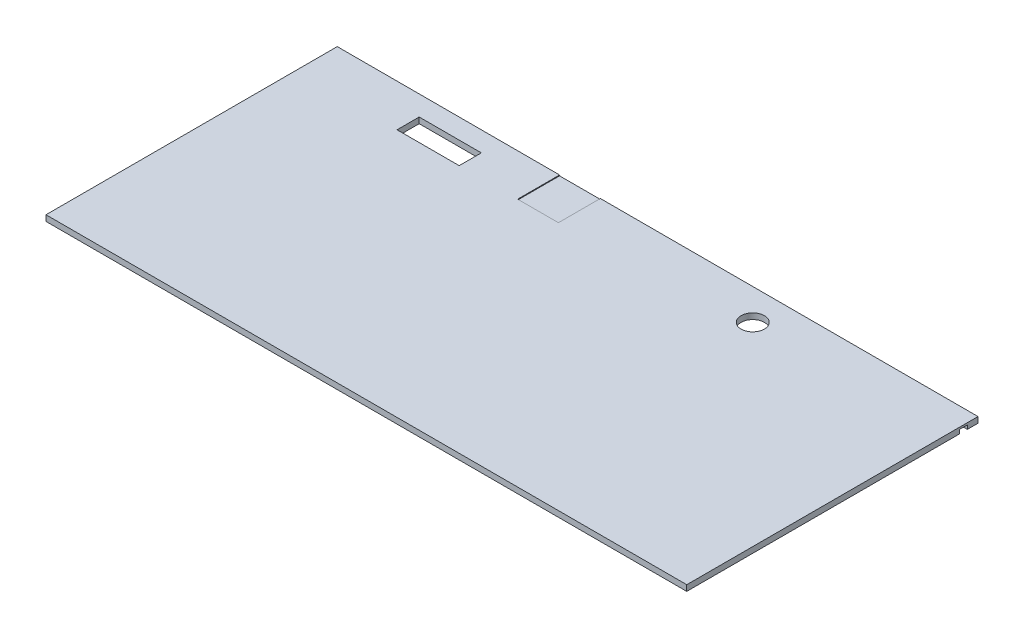
from build123d import *

# Parameters (mm, degrees)
SKETCH1_W           = 160
SKETCH1_H           = 57
SKETCH1_R           = 30
SKETCH1_W_2         = 105
SKETCH1_H_2         = 108
BOSS_EXTRUDE1_DEPTH = 15
CUT_EXTRUDE1_START  = -572.5
SKETCH2_W           = 20
SKETCH2_H           = 10
CUT_EXTRUDE1_DEPTH  = 497.5
CUT_EXTRUDE2_START  = -677.5
SKETCH2_3_W         = 20
SKETCH2_3_H         = 10
CUT_EXTRUDE2_DEPTH  = 973.5
CUT_EXTRUDE3_START  = 13
SKETCH1_3_W         = 105
SKETCH1_3_H         = 108
CUT_EXTRUDE3_DEPTH  = 3
CUT_EXTRUDE4_START  = -572.5
SKETCH2_4_W         = 20
SKETCH2_4_H         = 10
CUT_EXTRUDE4_DEPTH  = 497.5
CUT_EXTRUDE5_START  = -1250
SKETCH2_5_W         = 20
SKETCH2_5_H         = 10
CUT_EXTRUDE5_DEPTH  = 572.5
SKETCH4_W           = 20
SKETCH4_H           = 20
CUT_EXTRUDE6_DEPTH  = 5
SKETCH3_W           = 20
SKETCH3_H           = 600
CUT_EXTRUDE7_DEPTH  = 10


with BuildPart() as part:
    # Sketch1 → Boss-Extrude1 (new body)
    with BuildSketch(Plane(origin=(0, 0, 0), x_dir=(1, 0, 0), z_dir=(0, 1, 0))):
        Polygon((-825, 375), (-825, -375), (825, -375), (825, 375), (-147.5, 375), (-147.5, 267), (-252.5, 267), (-252.5, 375), align=None)
        with Locations((-482.5, 295)):
            Rectangle(SKETCH1_W, SKETCH1_H, mode=Mode.SUBTRACT)
        with Locations((325, 295)):
            Circle(SKETCH1_R, mode=Mode.SUBTRACT)
        with Locations((-200, 321)):
            Rectangle(SKETCH1_W_2, SKETCH1_H_2)
    extrude(amount=BOSS_EXTRUDE1_DEPTH)

    # Sketch2 → Cut-Extrude1 (cut)
    with BuildSketch(Plane.ZY.offset(825).offset(CUT_EXTRUDE1_START)):
        with Locations((-337.5, 5)):
            Rectangle(SKETCH2_W, SKETCH2_H)
    extrude(amount=CUT_EXTRUDE1_DEPTH, mode=Mode.SUBTRACT)

    # Sketch2_3 → Cut-Extrude2 (cut, through all)
    with BuildSketch(Plane.ZY.offset(825).offset(CUT_EXTRUDE2_START)):
        with Locations((-337.5, 5)):
            Rectangle(SKETCH2_3_W, SKETCH2_3_H)
    extrude(amount=-CUT_EXTRUDE2_DEPTH, mode=Mode.SUBTRACT)

    # Sketch1_3 → Cut-Extrude3 (cut, through all)
    with BuildSketch(Plane(origin=(0, 0, 0), x_dir=(1, 0, 0), z_dir=(0, 1, 0)).offset(CUT_EXTRUDE3_START)):
        with Locations((-200, 321)):
            Rectangle(SKETCH1_3_W, SKETCH1_3_H)
    extrude(amount=CUT_EXTRUDE3_DEPTH, mode=Mode.SUBTRACT)

    # Sketch2_4 → Cut-Extrude4 (cut)
    with BuildSketch(Plane.ZY.offset(825).offset(CUT_EXTRUDE4_START)):
        with Locations((337.5, 5)):
            Rectangle(SKETCH2_4_W, SKETCH2_4_H)
    extrude(amount=CUT_EXTRUDE4_DEPTH, mode=Mode.SUBTRACT)

    # Sketch2_5 → Cut-Extrude5 (cut)
    with BuildSketch(Plane.ZY.offset(825).offset(CUT_EXTRUDE5_START)):
        with Locations((337.5, 5)):
            Rectangle(SKETCH2_5_W, SKETCH2_5_H)
    extrude(amount=CUT_EXTRUDE5_DEPTH, mode=Mode.SUBTRACT)

    # Sketch4 → Cut-Extrude6 (cut)
    with BuildSketch(Plane.XZ):
        with Locations((-242.5, -337.5)):
            Rectangle(SKETCH4_W, SKETCH4_H)
        with Locations((-157.5, -337.5)):
            Rectangle(SKETCH4_W, SKETCH4_H)
        with Locations((-157.5, 337.5)):
            Rectangle(SKETCH4_W, SKETCH4_H)
        with Locations((-242.5, 337.5)):
            Rectangle(SKETCH4_W, SKETCH4_H)
    extrude(amount=-CUT_EXTRUDE6_DEPTH, mode=Mode.SUBTRACT)

    # Sketch3 → Cut-Extrude7 (cut)
    with BuildSketch(Plane.XZ):
        with Locations((-787.5, 0)):
            Rectangle(SKETCH3_W, SKETCH3_H)
    extrude(amount=-CUT_EXTRUDE7_DEPTH, mode=Mode.SUBTRACT)


solid = part.part
